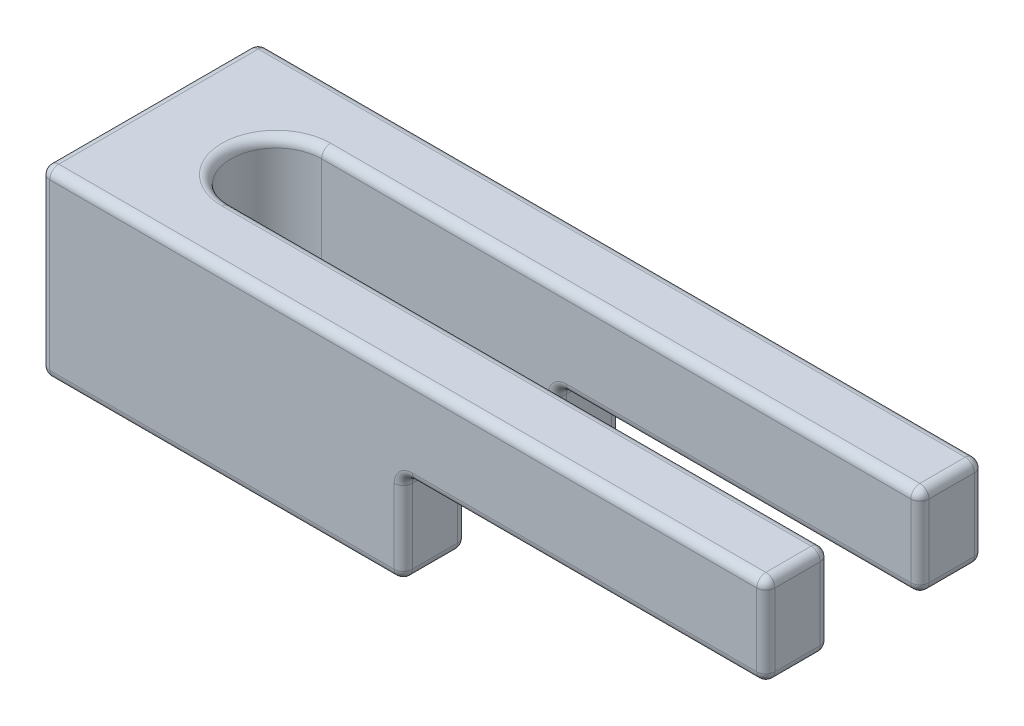
from build123d import *

# Parameters (mm, degrees)
ESQUISSE1_W             = 190
ESQUISSE1_H             = 12
BOSS_EXTRU_1_DEPTH      = 2.5
BOSS_EXTRU_3_DEPTH      = 5.1
ENL_V_START             = -40
ESQUISSE5_W             = 12
ESQUISSE5_H             = 10.1
ENL_V_MAT_EXTRU_1_DEPTH = 151
CONG_1_R                = 0.5


with BuildPart() as part:
    # Esquisse1 → Boss.-Extru.1 (new body, symmetric)
    with BuildSketch(Plane(origin=(0, 0, 0), x_dir=(1, 0, 0), z_dir=(0, 1, 0))):
        Rectangle(ESQUISSE1_W, ESQUISSE1_H)
        with BuildLine():
            Line((-88, 2.5), (88, 2.5))
            ThreePointArc((88, 2.5), (90.5, 0), (88, -2.5))
            Line((88, -2.5), (-88, -2.5))
            ThreePointArc((-88, -2.5), (-90.5, 0), (-88, 2.5))
        make_face(mode=Mode.SUBTRACT)
    extrude(amount=BOSS_EXTRU_1_DEPTH, both=True)

    # Esquisse4 → Boss.-Extru.3 (add)
    with BuildSketch(Plane.XZ.offset(2.5)):
        with BuildLine():
            Line((-95, 6), (-75, 6))
            Line((-75, 6), (-75, 2.5))
            Line((-75, 2.5), (-88, 2.5))
            ThreePointArc((-88, 2.5), (-90.5, 0), (-88, -2.5))
            Line((-88, -2.5), (-75, -2.5))
            Line((-75, -2.5), (-75, -6))
            Line((-75, -6), (-95, -6))
            Line((-95, -6), (-95, 6))
        make_face()
    boss_extru_3 = extrude(amount=BOSS_EXTRU_3_DEPTH)

    # Symétrie2: Boss.-Extru.3 across plane
    add(boss_extru_3.mirror(Plane(origin=(0, 0, 0), x_dir=(0, 0, 1), z_dir=(1, 0, 0))))

    # Esquisse5 → Enlèv. mat.-Extru.1 (cut, through all)
    with BuildSketch(Plane.ZY.offset(95).offset(ENL_V_START)):
        with Locations((0, -2.55)):
            Rectangle(ESQUISSE5_W, ESQUISSE5_H)
    extrude(amount=-ENL_V_MAT_EXTRU_1_DEPTH, mode=Mode.SUBTRACT)

    # Congé1
    cong_1_edges = [part.edges().sort_by_distance(p)[0] for p in [
        (-95, 2.5, 0),
        (-90.5, 2.5, 0),
        (-75, 2.5, 6),
        (-71.5, 2.5, 2.5),
        (-65, -2.5, 6),
        (-65, -2.5, 2.5),
        (-75, -2.5, -4.25),
        (-75, -5.05, -6),
        (-75, -5.05, -2.5),
        (-75, -2.5, 4.25),
        (-75, -5.05, 2.5),
        (-75, -5.05, 6),
        (-95, -7.6, 0),
        (-85, -7.6, -6),
        (-75, -7.6, -4.25),
        (-81.5, -7.6, -2.5),
        (-90.5, -7.6, 0),
        (-81.5, -7.6, 2.5),
        (-75, -7.6, 4.25),
        (-85, -7.6, 6),
        (-65, -2.5, -2.5),
        (-71.5, 2.5, -2.5),
        (-55, 0, -2.5),
        (-65, -2.5, -6),
        (-95, -2.55, 6),
        (-75, 2.5, -6),
        (-95, -2.55, -6),
        (-55, -2.5, 4.25),
        (-55, 0, 2.5),
        (-55, -2.5, -4.25),
        (-55, 0, 6),
        (-55, 2.5, 4.25),
        (-55, 2.5, -4.25),
        (-55, 0, -6),
    ]]
    fillet(cong_1_edges, radius=CONG_1_R)


solid = part.part
